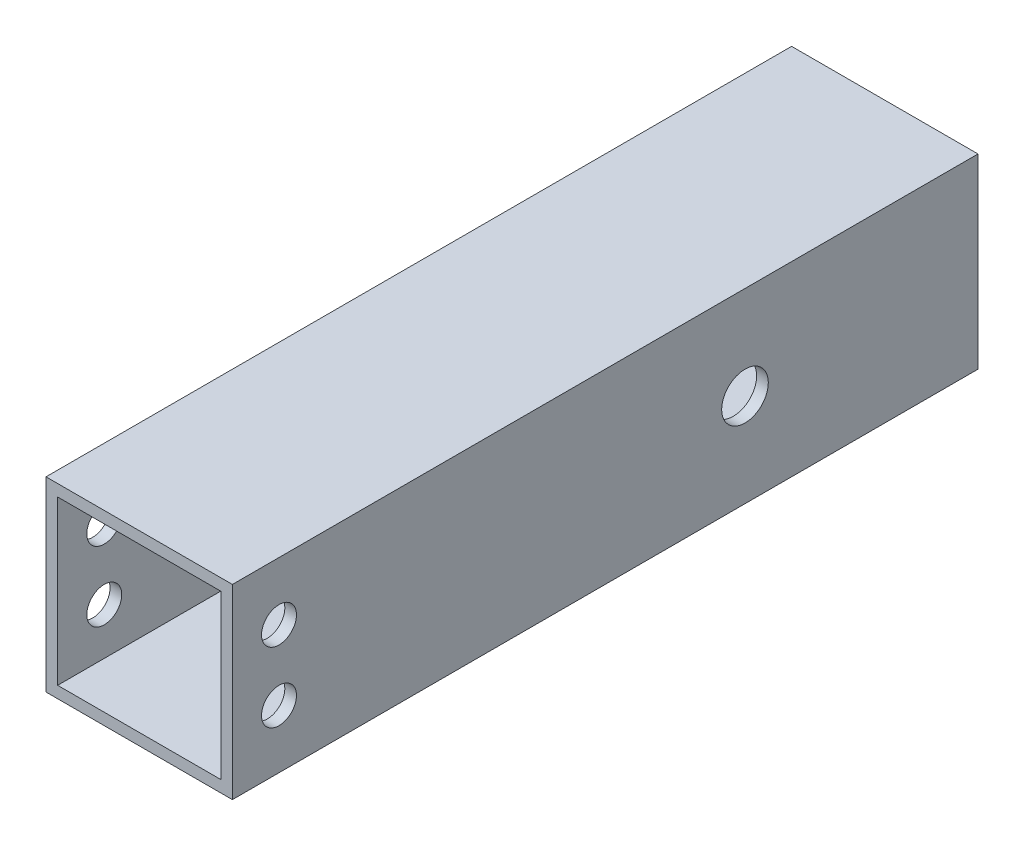
from build123d import *

# Parameters (mm, degrees)
SKETCH1_W           = 25.4
SKETCH1_H           = 25.4
SKETCH1_W_2         = 22.225
SKETCH1_H_2         = 22.225
BOSS_EXTRUDE1_DEPTH = 101.6
SKETCH2_R           = 2.38125
SKETCH2_R_2         = 3.175
CUT_EXTRUDE1_DEPTH  = 25.4


with BuildPart() as part:
    # Sketch1 → Boss-Extrude1 (new body)
    with BuildSketch(Plane.XY):
        Rectangle(SKETCH1_W, SKETCH1_H)
        Rectangle(SKETCH1_W_2, SKETCH1_H_2, mode=Mode.SUBTRACT)
    extrude(amount=BOSS_EXTRUDE1_DEPTH)

    # Sketch2 → Cut-Extrude1 (cut)
    with BuildSketch(Plane(origin=(12.7, 0, 0), x_dir=(0, 0, -1), z_dir=(1, 0, 0))):
        with Locations((-95.25, 4.7625)):
            Circle(SKETCH2_R)
        with Locations((-95.25, -4.7625)):
            Circle(SKETCH2_R)
        with Locations((-31.75, 0)):
            Circle(SKETCH2_R_2)
    extrude(amount=-CUT_EXTRUDE1_DEPTH, mode=Mode.SUBTRACT)


solid = part.part
